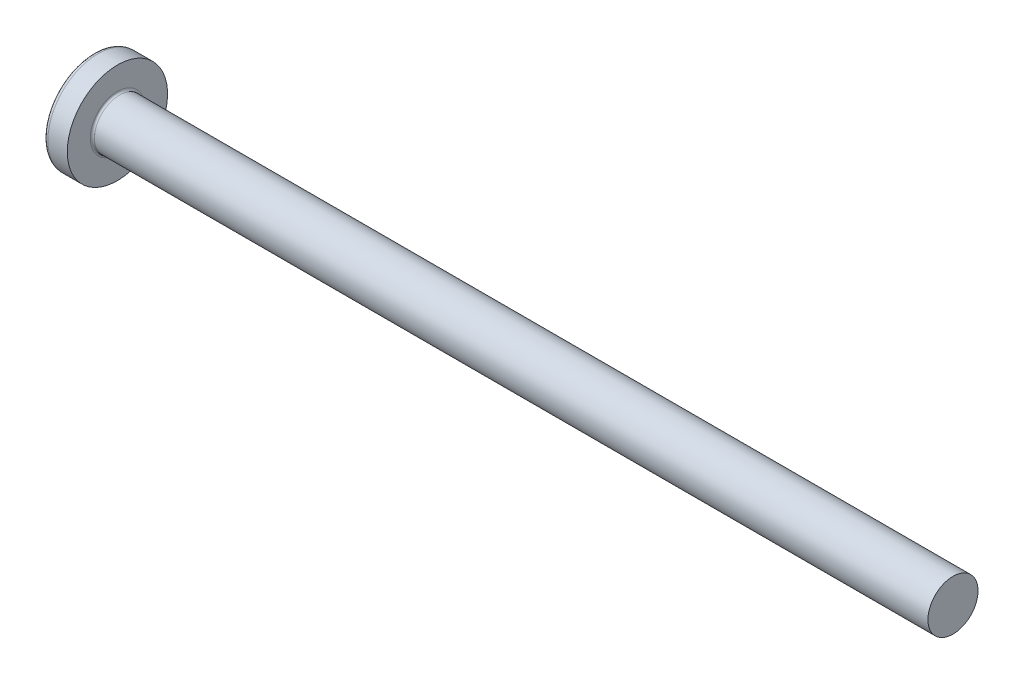
from build123d import *

# Parameters (mm, degrees)
FILLET1_R    = 0.25
SKETCH3_W    = 1.42
SKETCH3_H    = 6.7
SKETCH4_W    = 1.42
SKETCH4_H    = 3.24981585
RECPAT_COUNT = 2
RECPAT_ANGLE = 90


with BuildPart() as part:
    # BodySke → Base-Revolve (revolve)
    with BuildSketch(Plane.XY):
        with BuildLine():
            Line((4.6, 3), (4.6, 6))
            Line((4.6, 6), (2.274716834, 6))
            ThreePointArc((2.274716834, 6), (2.026424569, 5.939532013), (1.833738725, 5.77167019))
            ThreePointArc((1.833738725, 5.77167019), (0.469454036, 3.027985077), (0, 0))
            Line((0, 0), (104.6, 0))
            Line((104.6, 0), (104.6, 3))
            Line((104.6, 3), (4.6, 3))
        make_face()
    revolve(axis=Axis((-25.4, 0, 0), (1, 0, 0)))

    # Fillet1
    fillet1_edges = [part.edges().sort_by_distance(p)[0] for p in [
        (4.6, -3, 0),
    ]]
    fillet(fillet1_edges, radius=FILLET1_R)

    # Sketch3 → Recess section 0
    with BuildSketch(Plane(origin=(0, 0, 0), x_dir=(0, 0, -1), z_dir=(1, 0, 0))):
        Rectangle(SKETCH3_W, SKETCH3_H)
    # Sketch4 → Recess section 1
    with BuildSketch(Plane(origin=(3.46, 0, 0), x_dir=(0, 0, -1), z_dir=(1, 0, 0))):
        Rectangle(SKETCH4_W, SKETCH4_H)
    recess = loft(mode=Mode.SUBTRACT)

    # RecPat: Recess ×2 about axis
    recpat_axis = Axis((0, 0, 0), (1, 0, 0))
    for i in range(1, RECPAT_COUNT):
        add(recess.rotate(recpat_axis, i * RECPAT_ANGLE / (RECPAT_COUNT - 1)), mode=Mode.SUBTRACT)

    # RecCorSke → RecessCore (revolve, cut)
    with BuildSketch(Plane.XY):
        Polygon((0, 0), (0, 1.522446769), (3.46, 1.2805), (3.876059671, 0), align=None)
    revolve(axis=Axis((-3.175, 0, 0), (1, 0, 0)), mode=Mode.SUBTRACT)


solid = part.part
